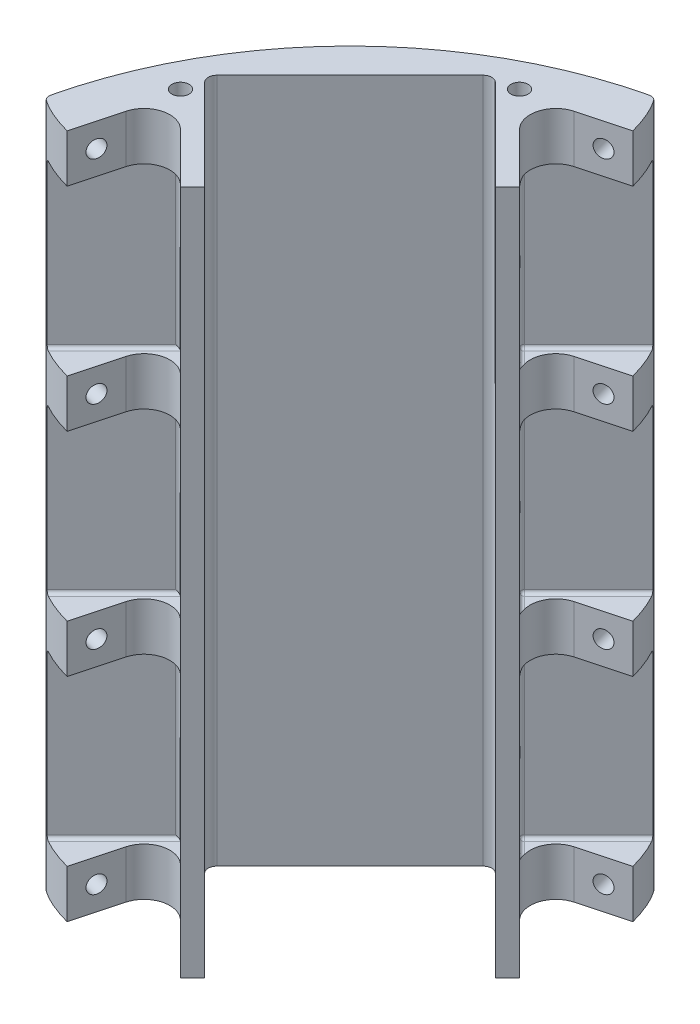
from build123d import *

# Parameters (mm, degrees)
CRADLE_DEPTH                               = 254
SKETCH1_R                                  = 3.175
CUT_EXTRUDE1_DEPTH                         = 12.7
EIGTH_INCH_FILLETS_INTERNAL_R              = 3.175
RADIAL_BOLT_HOLDER_DEPTH                   = 17.78
SKETCH6_R                                  = 3.175
BOLT_HOLE_DEPTH                            = 296.396340525
PATTERN_THE_RADIAL_BOLT_HOLDER_COUNT       = 4
PATTERN_THE_RADIAL_BOLT_HOLDER_PITCH       = 78.74
MIRROR_AFOREMENTIONED_PATTERN_COPY_1_DEPTH = 17.78
MIRROR_AFOREMENTIONED_PATTERN_COPY_2_DEPTH = 17.78
MIRROR_AFOREMENTIONED_PATTERN_COPY_3_DEPTH = 17.78
MIRROR_AFOREMENTIONED_PATTERN_COPY_4_SKE_R = 3.175
MIRROR_AFOREMENTIONED_PATTERN_COPY_4_DEPTH = 296.396340525
MIRROR_AFOREMENTIONED_PATTERN_COPY_5_SKE_R = 3.175
MIRROR_AFOREMENTIONED_PATTERN_COPY_5_DEPTH = 296.396340525
MIRROR_AFOREMENTIONED_PATTERN_COPY_6_SKE_R = 3.175
MIRROR_AFOREMENTIONED_PATTERN_COPY_6_DEPTH = 296.396340525
MIRROR_AFOREMENTIONED_PATTERN_COPY_7_DEPTH = 17.78
MIRROR_AFOREMENTIONED_PATTERN_COPY_8_SKE_R = 3.175
MIRROR_AFOREMENTIONED_PATTERN_COPY_8_DEPTH = 296.396340525
SKETCH4_R                                  = 1.27
WIRE_HOLES_DEPTH                           = 331.107912168
WEIGHT_REDUCING_CUT_DEPTH                  = 328.901850675
BOTTOM_EDGE_FILLET_R                       = 2.54
BOTTOM_EDGE_FILLET_OF_MIRROR2_R            = 2.54
FILLETS_FOR_RADIAL_BOLT_HOLDERS_R          = 1.27


with BuildPart() as part:
    # Base → Cradle (new body)
    with BuildSketch(Plane(origin=(0, 0, 0), x_dir=(1, 0, 0), z_dir=(0, 1, 0))):
        with BuildLine():
            Line((-27.68192265, 146.634960986), (-55.727545394, 118.589338242))
            Line((-55.727545394, 118.589338242), (-28.786777031, 91.648569879))
            Line((-28.786777031, 91.648569879), (-33.276905092, 87.158441818))
            Line((-33.276905092, 87.158441818), (-69.197929576, 123.079466302))
            Line((-69.197929576, 123.079466302), (-123.079466302, 69.197929576))
            Line((-123.079466302, 69.197929576), (-87.158441818, 33.276905092))
            Line((-87.158441818, 33.276905092), (-91.648569879, 28.786777031))
            Line((-91.648569879, 28.786777031), (-118.589338242, 55.727545394))
            Line((-118.589338242, 55.727545394), (-146.634960986, 27.68192265))
            ThreePointArc((-146.634960986, 27.68192265), (-105.518009423, 105.518009423), (-27.68192265, 146.634960986))
        make_face()
    extrude(amount=CRADLE_DEPTH)

    # Sketch1 → Cut-Extrude1 (cut)
    with BuildSketch(Plane(origin=(0, 254, 0), x_dir=(1, 0, 0), z_dir=(0, 1, 0))):
        with Locations((-60.217673455, 123.079466302)):
            Circle(SKETCH1_R)
        with Locations((-123.079466302, 60.217673455)):
            Circle(SKETCH1_R)
    cut_extrude1 = extrude(amount=-CUT_EXTRUDE1_DEPTH, mode=Mode.SUBTRACT)

    # Mirror1: Cut-Extrude1 across plane
    add(cut_extrude1.mirror(Plane.ZX.offset(127)), mode=Mode.SUBTRACT)

    # Eigth Inch Fillets _Internal
    eigth_inch_fillets_internal_edges = [part.edges().sort_by_distance(p)[0] for p in [
        (-123.079466302, 127, -69.197929576),
        (-69.197929576, 127, -123.079466302),
    ]]
    fillet(eigth_inch_fillets_internal_edges, radius=EIGTH_INCH_FILLETS_INTERNAL_R)

    # Sketch5 → Radial Bolt Holder (add)
    with BuildSketch(Plane.XZ):
        with BuildLine():
            ThreePointArc((-110.279015993, -47.417223145), (-119.461210338, -49.727135245), (-126.121955812, -42.997881452))
            Line((-126.121955812, -42.997881452), (-130.723758434, -25.82372026))
            ThreePointArc((-130.723758434, -25.82372026), (-138.611629309, -27.332775578), (-146.634960986, -27.68192265))
            Line((-146.634960986, -27.68192265), (-118.589338242, -55.727545394))
            Line((-118.589338242, -55.727545394), (-110.279015993, -47.417223145))
        make_face()
    radial_bolt_holder = extrude(amount=-RADIAL_BOLT_HOLDER_DEPTH)

    # Sketch6 → Bolt Hole (cut, through all)
    with BuildSketch(Plane(origin=(-128.422857123, 0, -34.410800856), x_dir=(0.2588190451025201, 0, -0.9659258262890685), z_dir=(0.9659258262890686, 0, 0.2588190451025201))):
        with Locations((0, 8.89)):
            Circle(SKETCH6_R)
    bolt_hole = extrude(amount=-BOLT_HOLE_DEPTH, mode=Mode.SUBTRACT)

    # Pattern the Radial Bolt Holder: Radial Bolt Holder, Bolt Hole ×4
    with Locations(*[(0, i * PATTERN_THE_RADIAL_BOLT_HOLDER_PITCH, 0) for i in range(1, PATTERN_THE_RADIAL_BOLT_HOLDER_COUNT)]):
        add(radial_bolt_holder)
        add(bolt_hole, mode=Mode.SUBTRACT)

    # Mirror Aforementioned Pattern copy 1 ske → Mirror Aforementioned Pattern copy 1 (add)
    with BuildSketch(Plane(origin=(0, 78.74, 0), x_dir=(0, 0, 1), z_dir=(0, -1, 0))):
        with BuildLine():
            ThreePointArc((-110.279015993, 47.417223145), (-119.461210338, 49.727135245), (-126.121955812, 42.997881452))
            Line((-126.121955812, 42.997881452), (-130.723758434, 25.82372026))
            ThreePointArc((-130.723758434, 25.82372026), (-138.611629309, 27.332775578), (-146.634960986, 27.68192265))
            Line((-146.634960986, 27.68192265), (-118.589338242, 55.727545394))
            Line((-118.589338242, 55.727545394), (-110.279015993, 47.417223145))
        make_face()
    extrude(amount=-MIRROR_AFOREMENTIONED_PATTERN_COPY_1_DEPTH)

    # Mirror Aforementioned Pattern copy 2 ske → Mirror Aforementioned Pattern copy 2 (add)
    with BuildSketch(Plane(origin=(0, 157.48, 0), x_dir=(0, 0, 1), z_dir=(0, -1, 0))):
        with BuildLine():
            ThreePointArc((-110.279015993, 47.417223145), (-119.461210338, 49.727135245), (-126.121955812, 42.997881452))
            Line((-126.121955812, 42.997881452), (-130.723758434, 25.82372026))
            ThreePointArc((-130.723758434, 25.82372026), (-138.611629309, 27.332775578), (-146.634960986, 27.68192265))
            Line((-146.634960986, 27.68192265), (-118.589338242, 55.727545394))
            Line((-118.589338242, 55.727545394), (-110.279015993, 47.417223145))
        make_face()
    extrude(amount=-MIRROR_AFOREMENTIONED_PATTERN_COPY_2_DEPTH)

    # Mirror Aforementioned Pattern copy 3 ske → Mirror Aforementioned Pattern copy 3 (add)
    with BuildSketch(Plane(origin=(0, 236.22, 0), x_dir=(0, 0, 1), z_dir=(0, -1, 0))):
        with BuildLine():
            ThreePointArc((-110.279015993, 47.417223145), (-119.461210338, 49.727135245), (-126.121955812, 42.997881452))
            Line((-126.121955812, 42.997881452), (-130.723758434, 25.82372026))
            ThreePointArc((-130.723758434, 25.82372026), (-138.611629309, 27.332775578), (-146.634960986, 27.68192265))
            Line((-146.634960986, 27.68192265), (-118.589338242, 55.727545394))
            Line((-118.589338242, 55.727545394), (-110.279015993, 47.417223145))
        make_face()
    extrude(amount=-MIRROR_AFOREMENTIONED_PATTERN_COPY_3_DEPTH)

    # Mirror Aforementioned Pattern copy 4 ske → Mirror Aforementioned Pattern copy 4 (cut, through all)
    with BuildSketch(Plane(origin=(-34.410800856, 78.74, -128.422857123), x_dir=(-0.9659258262890684, 0, 0.2588190451025205), z_dir=(0.2588190451025205, 0, 0.9659258262890685))):
        with Locations((0, -8.89)):
            Circle(MIRROR_AFOREMENTIONED_PATTERN_COPY_4_SKE_R)
    extrude(amount=-MIRROR_AFOREMENTIONED_PATTERN_COPY_4_DEPTH, mode=Mode.SUBTRACT)

    # Mirror Aforementioned Pattern copy 5 ske → Mirror Aforementioned Pattern copy 5 (cut, through all)
    with BuildSketch(Plane(origin=(-34.410800856, 157.48, -128.422857123), x_dir=(-0.9659258262890684, 0, 0.2588190451025205), z_dir=(0.2588190451025205, 0, 0.9659258262890685))):
        with Locations((0, -8.89)):
            Circle(MIRROR_AFOREMENTIONED_PATTERN_COPY_5_SKE_R)
    extrude(amount=-MIRROR_AFOREMENTIONED_PATTERN_COPY_5_DEPTH, mode=Mode.SUBTRACT)

    # Mirror Aforementioned Pattern copy 6 ske → Mirror Aforementioned Pattern copy 6 (cut, through all)
    with BuildSketch(Plane(origin=(-34.410800856, 236.22, -128.422857123), x_dir=(-0.9659258262890684, 0, 0.2588190451025205), z_dir=(0.2588190451025205, 0, 0.9659258262890685))):
        with Locations((0, -8.89)):
            Circle(MIRROR_AFOREMENTIONED_PATTERN_COPY_6_SKE_R)
    extrude(amount=-MIRROR_AFOREMENTIONED_PATTERN_COPY_6_DEPTH, mode=Mode.SUBTRACT)

    # Mirror Aforementioned Pattern copy 7 ske → Mirror Aforementioned Pattern copy 7 (add)
    with BuildSketch(Plane(origin=(0, 0, 0), x_dir=(0, 0, 1), z_dir=(0, -1, 0))):
        with BuildLine():
            ThreePointArc((-110.279015993, 47.417223145), (-119.461210338, 49.727135245), (-126.121955812, 42.997881452))
            Line((-126.121955812, 42.997881452), (-130.723758434, 25.82372026))
            ThreePointArc((-130.723758434, 25.82372026), (-138.611629309, 27.332775578), (-146.634960986, 27.68192265))
            Line((-146.634960986, 27.68192265), (-118.589338242, 55.727545394))
            Line((-118.589338242, 55.727545394), (-110.279015993, 47.417223145))
        make_face()
    extrude(amount=-MIRROR_AFOREMENTIONED_PATTERN_COPY_7_DEPTH)

    # Mirror Aforementioned Pattern copy 8 ske → Mirror Aforementioned Pattern copy 8 (cut, through all)
    with BuildSketch(Plane(origin=(-34.410800856, 0, -128.422857123), x_dir=(-0.9659258262890684, 0, 0.2588190451025205), z_dir=(0.2588190451025205, 0, 0.9659258262890685))):
        with Locations((0, -8.89)):
            Circle(MIRROR_AFOREMENTIONED_PATTERN_COPY_8_SKE_R)
    extrude(amount=-MIRROR_AFOREMENTIONED_PATTERN_COPY_8_DEPTH, mode=Mode.SUBTRACT)

    # Sketch4 → Wire Holes (cut, through all)
    with BuildSketch(Plane(origin=(26.940768363, 0, -26.940768363), x_dir=(0.7071067811865476, 0, 0.7071067811865476), z_dir=(-0.7071067811865476, 0, 0.7071067811865476))):
        with Locations((-108.973150495, 127)):
            Circle(SKETCH4_R)
        with Locations((-108.973150495, 101.6)):
            Circle(SKETCH4_R)
        with Locations((-108.973150495, 76.2)):
            Circle(SKETCH4_R)
        with Locations((-108.973150495, 50.8)):
            Circle(SKETCH4_R)
        with Locations((-108.973150495, 25.4)):
            Circle(SKETCH4_R)
        with Locations((-108.973150495, 152.4)):
            Circle(SKETCH4_R)
        with Locations((-108.973150495, 177.8)):
            Circle(SKETCH4_R)
        with Locations((-108.973150495, 203.2)):
            Circle(SKETCH4_R)
        with Locations((-96.273150495, 25.4)):
            Circle(SKETCH4_R)
        with Locations((-96.273150495, 50.8)):
            Circle(SKETCH4_R)
        with Locations((-96.273150495, 76.2)):
            Circle(SKETCH4_R)
        with Locations((-96.273150495, 101.6)):
            Circle(SKETCH4_R)
        with Locations((-96.273150495, 127)):
            Circle(SKETCH4_R)
        with Locations((-96.273150495, 152.4)):
            Circle(SKETCH4_R)
        with Locations((-96.273150495, 177.8)):
            Circle(SKETCH4_R)
        with Locations((-96.273150495, 203.2)):
            Circle(SKETCH4_R)
        with Locations((-96.273150495, 228.6)):
            Circle(SKETCH4_R)
        with Locations((-108.973150495, 228.6)):
            Circle(SKETCH4_R)
    extrude(amount=-WIRE_HOLES_DEPTH, mode=Mode.SUBTRACT)

    # Sketch7 → Weight Reducing Cut (cut, through all)
    with BuildSketch(Plane.XZ):
        with BuildLine():
            ThreePointArc((-146.634960986, -27.68192265), (-146.135484019, -30.20796146), (-145.592495065, -32.725005819))
            add(Edge.make_bspline(
                [(-130.723758434, -25.82372026), (-141.074538832, -28.597203509), (-145.592495065, -32.725005819)],
                knots=[1.570796327, 1.570796327, 1.570796327, 2.598121945, 2.598121945, 2.598121945], degree=2, weights=[1, 0.80611504, 0.862436376]))
            ThreePointArc((-130.723758434, -25.82372026), (-138.611629309, -27.332775578), (-146.634960986, -27.68192265))
        make_face()
    weight_reducing_cut = extrude(amount=-WEIGHT_REDUCING_CUT_DEPTH, mode=Mode.SUBTRACT)

    # Bottom Edge Fillet
    bottom_edge_fillet_edges = [part.edges().sort_by_distance(p)[0] for p in [
        (-145.592495065, 127, -32.725005819),
    ]]
    fillet(bottom_edge_fillet_edges, radius=BOTTOM_EDGE_FILLET_R)

    # Mirror2: Weight Reducing Cut across plane
    add(weight_reducing_cut.mirror(Plane(origin=(0, 0, 0), x_dir=(0.7071067811865477, 0, 0.7071067811865474), z_dir=(-0.7071067811865474, 0, 0.7071067811865477))), mode=Mode.SUBTRACT)

    # Bottom Edge Fillet of Mirror2
    bottom_edge_fillet_of_mirror2_edges = [part.edges().sort_by_distance(p)[0] for p in [
        (-32.725005819, 127, -145.592495065),
    ]]
    fillet(bottom_edge_fillet_of_mirror2_edges, radius=BOTTOM_EDGE_FILLET_OF_MIRROR2_R)

    # Fillets for Radial Bolt Holders
    fillets_for_radial_bolt_holders_edges = [part.edges().sort_by_distance(p)[0] for p in [
        (-43.368335905, 236.22, -130.948547731),
        (-51.57238427, 236.22, -114.434177117),
        (-55.727545394, 205.74, -118.589338242),
        (-43.368335905, 175.26, -130.948547731),
        (-51.57238427, 175.26, -114.434177117),
        (-43.368335905, 157.48, -130.948547731),
        (-51.57238427, 157.48, -114.434177117),
        (-55.727545394, 127, -118.589338242),
        (-51.57238427, 96.52, -114.434177117),
        (-43.368335905, 96.52, -130.948547731),
        (-43.368335905, 78.74, -130.948547731),
        (-51.57238427, 78.74, -114.434177117),
        (-55.727545394, 48.26, -118.589338242),
        (-43.368335905, 17.78, -130.948547731),
        (-51.57238427, 17.78, -114.434177117),
        (-130.948547731, 17.78, -43.368335905),
        (-118.589338242, 48.26, -55.727545394),
        (-130.948547731, 78.74, -43.368335905),
        (-130.948547731, 96.52, -43.368335905),
        (-118.589338242, 127, -55.727545394),
        (-130.948547731, 157.48, -43.368335905),
        (-130.948547731, 175.26, -43.368335905),
        (-118.589338242, 205.74, -55.727545394),
        (-130.948547731, 236.22, -43.368335905),
    ]]
    fillet(fillets_for_radial_bolt_holders_edges, radius=FILLETS_FOR_RADIAL_BOLT_HOLDERS_R)


solid = part.part
